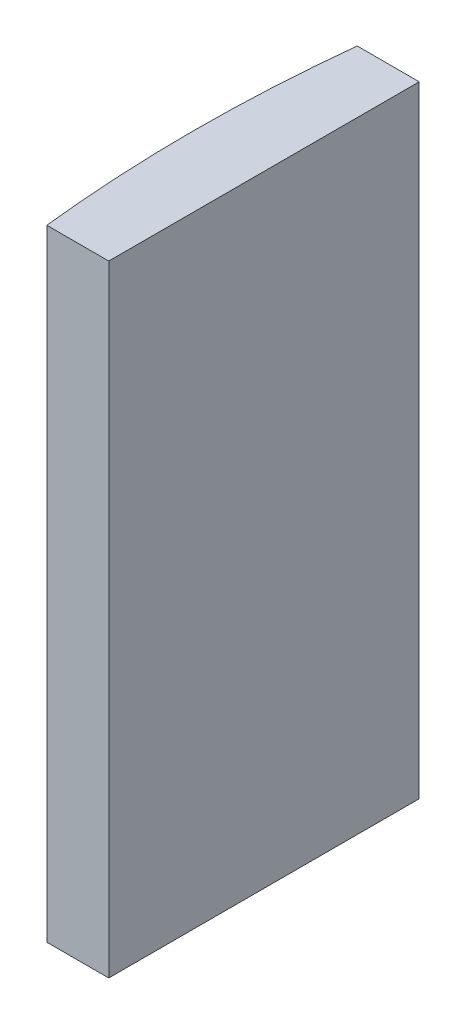
from build123d import *

# Parameters (mm, degrees)
EXTRUDE_1_DEPTH = 20


with BuildPart() as part:
    # 草图1 → 凸台-拉伸1 (new body)
    with BuildSketch(Plane(origin=(0, 0, 0), x_dir=(1, 0, 0), z_dir=(0, 1, 0))):
        with BuildLine():
            Line((-41.221352139, 5), (-39.224795665, 5))
            Line((-39.224795665, 5), (-39.224795665, -5))
            Line((-39.224795665, -5), (-41.221352139, -5))
            ThreePointArc((-41.221352139, -5), (-41.494795665, 0), (-41.221352139, 5))
        make_face()
    extrude(amount=EXTRUDE_1_DEPTH)


solid = part.part
